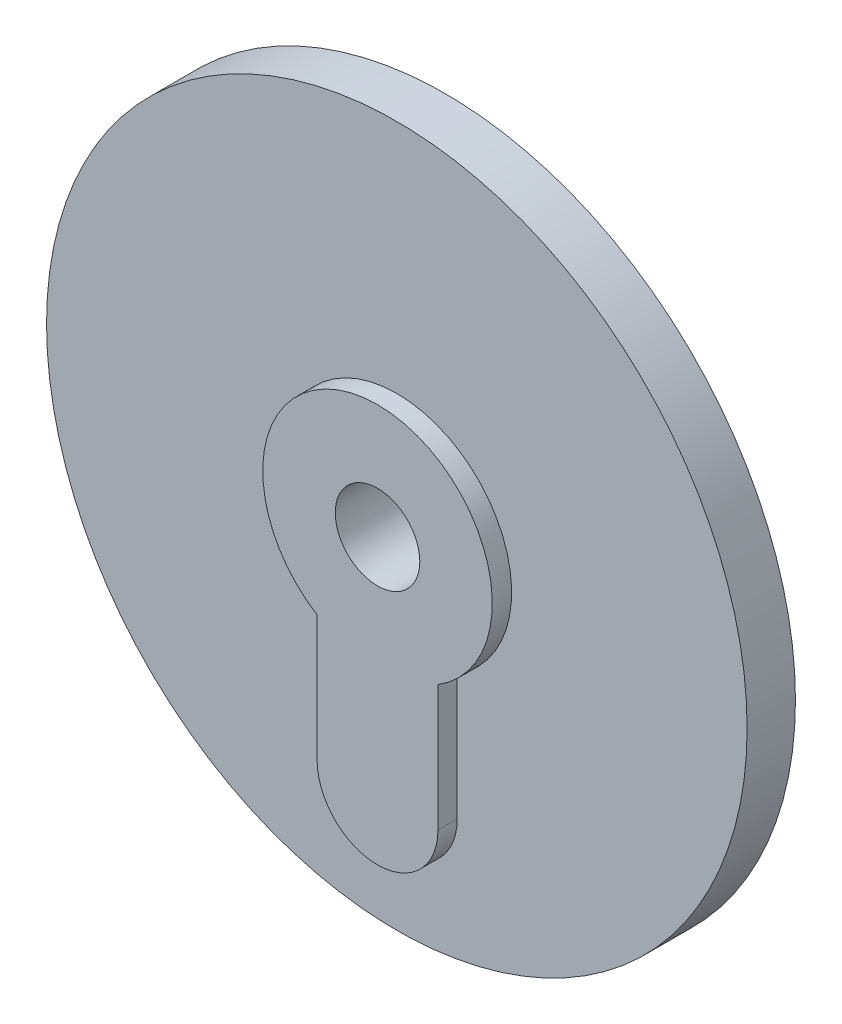
from build123d import *

# Parameters (mm, degrees)
SKETCH_1_R          = 14.5
EXTRUDE_1_DEPTH     = 2
EXTRUDE_START       = 2
EXTRUDE_2_DEPTH     = 0.8
SKETCH_1_4_R        = 1.75
CUT_EXTRUDE_1_DEPTH = 2.8


with BuildPart() as part:
    # Эскиз1 → Бобышка-Вытянуть1 (new body)
    with BuildSketch(Plane.XY):
        Circle(SKETCH_1_R)
    extrude(amount=EXTRUDE_1_DEPTH)

    # Эскиз1<3> → Бобышка-Вытянуть2 (add)
    with BuildSketch(Plane.XY.offset(EXTRUDE_START)):
        with BuildLine():
            Line((-2.5, -4.038873605), (-2.5, -9.25))
            ThreePointArc((-2.5, -9.25), (0, -11.75), (2.5, -9.25))
            Line((2.5, -9.25), (2.5, -4.038873605))
            ThreePointArc((2.5, -4.038873605), (0, 4.75), (-2.5, -4.038873605))
        make_face()
    extrude(amount=EXTRUDE_2_DEPTH)

    # Эскиз1<4> → Вырез-Вытянуть1 (cut)
    with BuildSketch(Plane.XY):
        Circle(SKETCH_1_4_R)
    extrude(amount=CUT_EXTRUDE_1_DEPTH, mode=Mode.SUBTRACT)


solid = part.part
